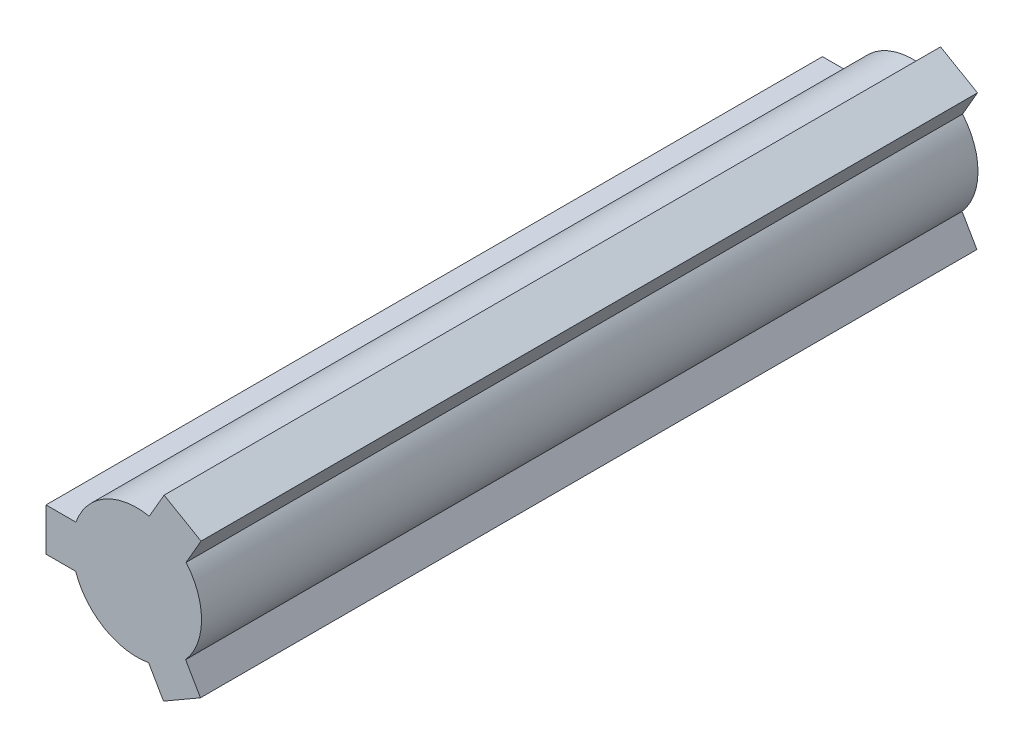
from build123d import *

# Parameters (mm, degrees)
EXTRUSION1_DEPTH = 38.1


with BuildPart() as part:
    # Sketch1 → Extrusion1 (new body)
    with BuildSketch(Plane.XY):
        with BuildLine():
            Line((2.416962135, 2.058863531), (3.1501433, 3.32877056))
            Line((3.1501433, 3.32877056), (1.336888207, 4.375653876))
            Line((1.336888207, 4.375653876), (0.609587103, 3.115931412))
            ThreePointArc((0.609587103, 3.115931412), (-1.572031269, 2.758503705), (-2.991509188, 1.063718843))
            Line((-2.991509188, 1.063718843), (-4.457871519, 1.063718843))
            Line((-4.457871519, 1.063718843), (-4.457871519, -1.030047788))
            Line((-4.457871519, -1.030047788), (-3.003269311, -1.030047788))
            ThreePointArc((-3.003269311, -1.030047788), (-1.60291865, -2.740670867), (0.574547053, -3.122582374))
            Line((0.574547053, -3.122582374), (1.307728219, -4.392489404))
            Line((1.307728219, -4.392489404), (3.120983311, -3.345606088))
            Line((3.120983311, -3.345606088), (2.393682207, -2.085883623))
            ThreePointArc((2.393682207, -2.085883623), (3.174949919, -0.017832838), (2.416962135, 2.058863531))
        make_face()
    extrude(amount=EXTRUSION1_DEPTH)


solid = part.part
